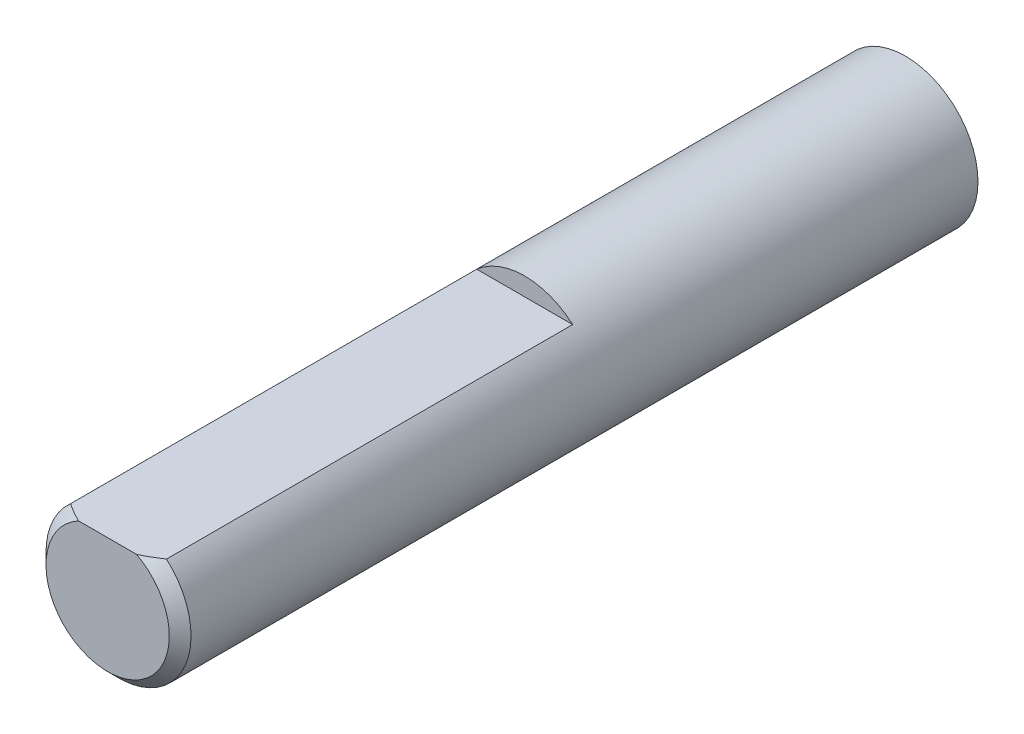
from build123d import *

# Parameters (mm, degrees)
ESQUISSE1_R             = 2
BOSS_EXTRU_1_DEPTH      = 12
BOSS_EXTRU_1_DEPTH_BACK = 10
CHANFREIN1_SIZE         = 0.3
ESQUISSE2_W             = 2.645751312
ESQUISSE2_H             = 0.5
ENL_V_MAT_EXTRU_1_DEPTH = 11.5


with BuildPart() as part:
    # Esquisse1 → Boss.-Extru.1 (new body, two sides)
    with BuildSketch(Plane.XY) as boss_extru_1_sk:
        Circle(ESQUISSE1_R)
    extrude(amount=BOSS_EXTRU_1_DEPTH)
    extrude(boss_extru_1_sk.sketch, amount=-BOSS_EXTRU_1_DEPTH_BACK)

    # Chanfrein1
    chanfrein1_edges = [part.edges().sort_by_distance(p)[0] for p in [
        (-2, 0, 12),
    ]]
    chamfer(chanfrein1_edges, length=CHANFREIN1_SIZE)

    # Esquisse2 → Enlèv. mat.-Extru.1 (cut)
    with BuildSketch(Plane.XY.offset(12)):
        with Locations((0, 1.75)):
            Rectangle(ESQUISSE2_W, ESQUISSE2_H)
    extrude(amount=-ENL_V_MAT_EXTRU_1_DEPTH, mode=Mode.SUBTRACT)


solid = part.part
